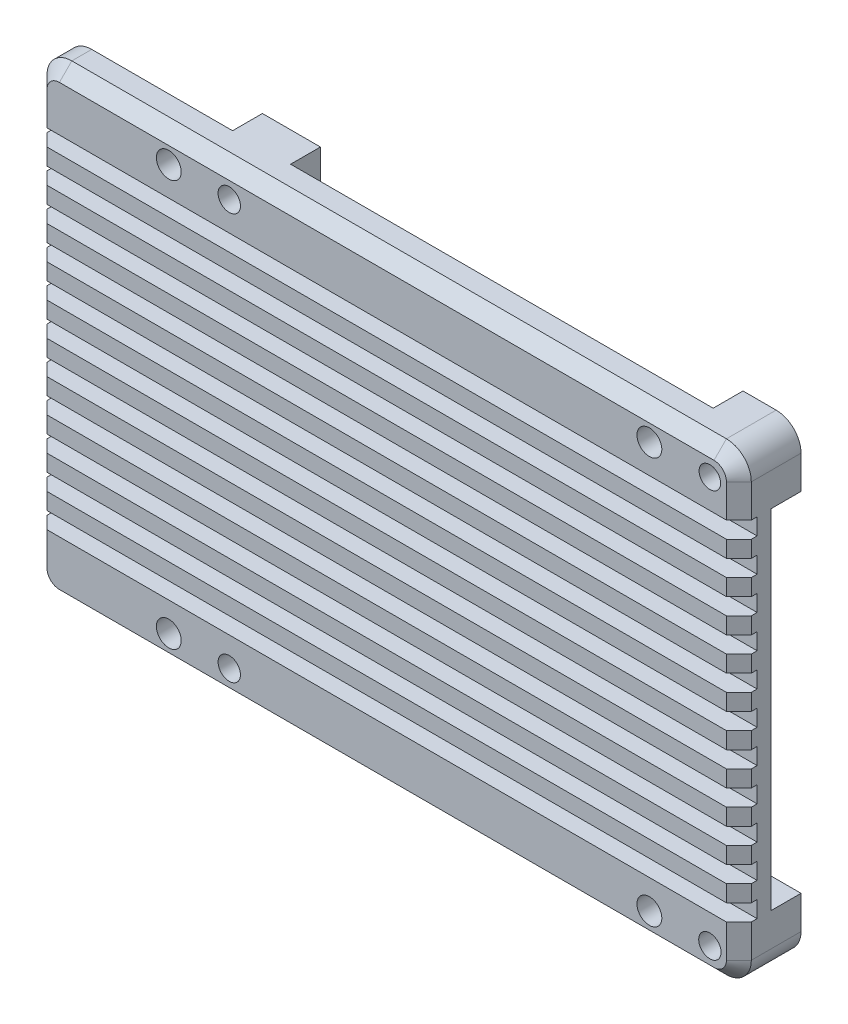
from build123d import *

# Parameters (mm, degrees)
SKETCH1_R           = 1.35
SKETCH1_R_2         = 1.3
BOSS_EXTRUDE1_DEPTH = 7.5
CUT_EXTRUDE1_DEPTH  = 3.6
CHAMFER1_SIZE       = 1.5
SKETCH3_W           = 85
SKETCH3_H           = 2
CUT_EXTRUDE2_DEPTH  = 2.2
CUT_EXTRUDE3_REACH  = 9.5
SKETCH4_R           = 1.5


with BuildPart() as part:
    # Sketch1 → Boss-Extrude1 (new body)
    with BuildSketch(Plane.XY):
        with BuildLine():
            Line((42.5, -25), (42.5, 25))
            ThreePointArc((42.5, 25), (41.621320344, 27.121320344), (39.5, 28))
            Line((39.5, 28), (-39.5, 28))
            ThreePointArc((-39.5, 28), (-41.621320344, 27.121320344), (-42.5, 25))
            Line((-42.5, 25), (-42.5, -25))
            ThreePointArc((-42.5, -25), (-41.621320344, -27.121320344), (-39.5, -28))
            Line((-39.5, -28), (39.5, -28))
            ThreePointArc((39.5, -28), (41.621320344, -27.121320344), (42.5, -25))
        make_face()
        with Locations((-19, -24.5)):
            Circle(SKETCH1_R, mode=Mode.SUBTRACT)
        with Locations((39, -24.5)):
            Circle(SKETCH1_R, mode=Mode.SUBTRACT)
        with Locations((39, 24.5)):
            Circle(SKETCH1_R_2, mode=Mode.SUBTRACT)
        with Locations((-19, 24.5)):
            Circle(SKETCH1_R, mode=Mode.SUBTRACT)
    extrude(amount=BOSS_EXTRUDE1_DEPTH)

    # Sketch2 → Cut-Extrude1 (cut)
    with BuildSketch(Plane(origin=(0, 0, 0), x_dir=(-1, 0, 0), z_dir=(0, 0, -1))):
        with BuildLine():
            Line((15.5, 28), (-35.5, 28))
            Line((-35.5, 28), (-35.5, 21))
            Line((-35.5, 21), (-42.5, 21))
            Line((-42.5, 21), (-42.5, -21))
            Line((-42.5, -21), (-35.5, -21))
            Line((-35.5, -21), (-35.5, -28))
            Line((-35.5, -28), (15.5, -28))
            Line((15.5, -28), (15.5, -21))
            Line((15.5, -21), (22.5, -21))
            Line((22.5, -21), (22.5, -28))
            Line((22.5, -28), (39.5, -28))
            ThreePointArc((39.5, -28), (41.621320344, -27.121320344), (42.5, -25))
            Line((42.5, -25), (42.5, 25))
            ThreePointArc((42.5, 25), (41.621320344, 27.121320344), (39.5, 28))
            Line((39.5, 28), (22.5, 28))
            Line((22.5, 28), (22.5, 21))
            Line((22.5, 21), (15.5, 21))
            Line((15.5, 21), (15.5, 28))
        make_face()
    extrude(amount=-CUT_EXTRUDE1_DEPTH, mode=Mode.SUBTRACT)

    # Chamfer1
    chamfer1_edges = [part.edges().sort_by_distance(p)[0] for p in [
        (41.621320344, 27.121320344, 7.5),
        (0, 28, 7.5),
        (-41.621320344, 27.121320344, 7.5),
        (-42.5, 0, 7.5),
        (-41.621320344, -27.121320344, 7.5),
        (0, -28, 7.5),
        (41.621320344, -27.121320344, 7.5),
        (42.5, 0, 7.5),
    ]]
    chamfer(chamfer1_edges, length=CHAMFER1_SIZE)

    # Sketch3 → Cut-Extrude2 (cut)
    with BuildSketch(Plane.XY.offset(7.5)):
        with Locations((0, 20)):
            Rectangle(SKETCH3_W, SKETCH3_H)
        with Locations((0, 16)):
            Rectangle(SKETCH3_W, SKETCH3_H)
        with Locations((0, 12)):
            Rectangle(SKETCH3_W, SKETCH3_H)
        with Locations((0, 8)):
            Rectangle(SKETCH3_W, SKETCH3_H)
        with Locations((0, 4)):
            Rectangle(SKETCH3_W, SKETCH3_H)
        Rectangle(SKETCH3_W, SKETCH3_H)
        with Locations((0, -4)):
            Rectangle(SKETCH3_W, SKETCH3_H)
        with Locations((0, -8)):
            Rectangle(SKETCH3_W, SKETCH3_H)
        with Locations((0, -12)):
            Rectangle(SKETCH3_W, SKETCH3_H)
        with Locations((0, -16)):
            Rectangle(SKETCH3_W, SKETCH3_H)
        with Locations((0, -20)):
            Rectangle(SKETCH3_W, SKETCH3_H)
    extrude(amount=-CUT_EXTRUDE2_DEPTH, mode=Mode.SUBTRACT)

    # Sketch4 → Cut-Extrude3 (cut, up to next)
    with BuildSketch(Plane.XY.offset(7.5), mode=Mode.PRIVATE) as cut_extrude3_sk1:
        with Locations((-26.3, 24.5)):
            Circle(SKETCH4_R)
    cut_extrude3_tool1 = extrude(cut_extrude3_sk1.sketch, amount=-CUT_EXTRUDE3_REACH, mode=Mode.PRIVATE) & part.part
    add(cut_extrude3_tool1.solids().sort_by_distance((-26.3, 24.5, 7.5))[0], mode=Mode.SUBTRACT)
    # Sketch4 → Cut-Extrude3 (cut, up to next)
    with BuildSketch(Plane.XY.offset(7.5), mode=Mode.PRIVATE) as cut_extrude3_sk2:
        with Locations((31.7, 24.5)):
            Circle(SKETCH4_R)
    cut_extrude3_tool2 = extrude(cut_extrude3_sk2.sketch, amount=-CUT_EXTRUDE3_REACH, mode=Mode.PRIVATE) & part.part
    add(cut_extrude3_tool2.solids().sort_by_distance((31.7, 24.5, 7.5))[0], mode=Mode.SUBTRACT)
    # Sketch4 → Cut-Extrude3 (cut, up to next)
    with BuildSketch(Plane.XY.offset(7.5), mode=Mode.PRIVATE) as cut_extrude3_sk3:
        with Locations((-26.3, -24.5)):
            Circle(SKETCH4_R)
    cut_extrude3_tool3 = extrude(cut_extrude3_sk3.sketch, amount=-CUT_EXTRUDE3_REACH, mode=Mode.PRIVATE) & part.part
    add(cut_extrude3_tool3.solids().sort_by_distance((-26.3, -24.5, 7.5))[0], mode=Mode.SUBTRACT)
    # Sketch4 → Cut-Extrude3 (cut, up to next)
    with BuildSketch(Plane.XY.offset(7.5), mode=Mode.PRIVATE) as cut_extrude3_sk4:
        with Locations((31.7, -24.5)):
            Circle(SKETCH4_R)
    cut_extrude3_tool4 = extrude(cut_extrude3_sk4.sketch, amount=-CUT_EXTRUDE3_REACH, mode=Mode.PRIVATE) & part.part
    add(cut_extrude3_tool4.solids().sort_by_distance((31.7, -24.5, 7.5))[0], mode=Mode.SUBTRACT)


solid = part.part
